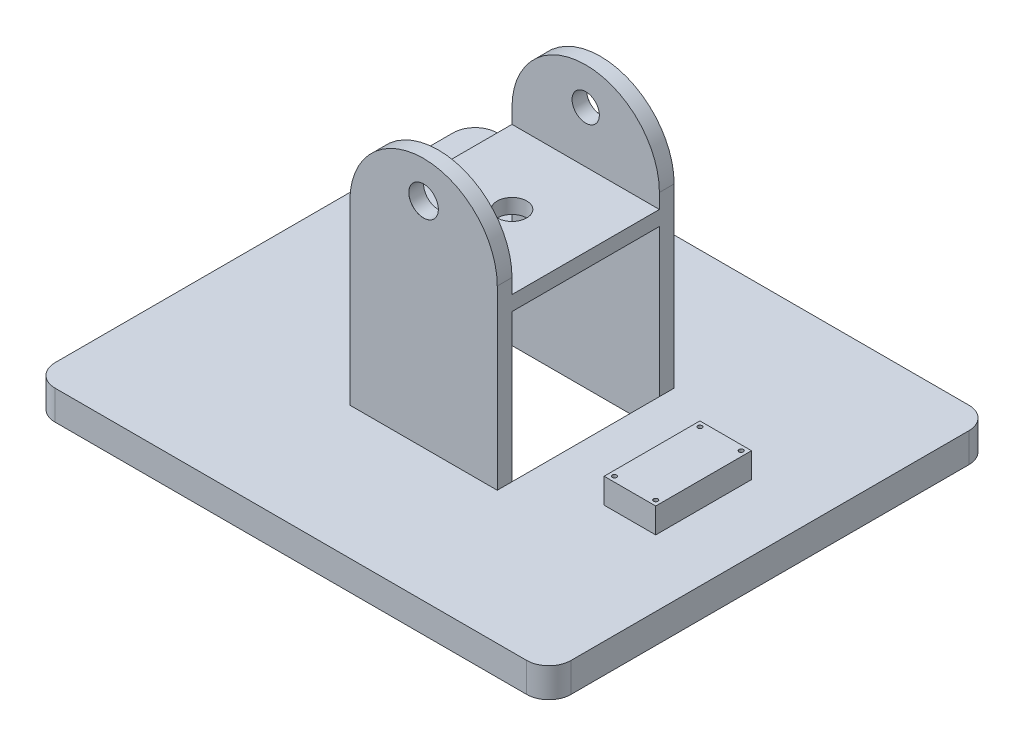
from build123d import *

# Parameters (mm, degrees)
SKETCH1_W                              = 350
SKETCH1_H                              = 300
BOSS_EXTRUDE1_DEPTH                    = 20
FILLET1_R                              = 15
SKETCH2_W                              = 100
SKETCH2_H                              = 100
CUT_EXTRUDE1_DEPTH                     = 20
BOSS_EXTRUDE2_DEPTH                    = 10
LPATTERN1_COUNT                        = 2
LPATTERN1_PITCH                        = 110
F_20_0_20_DIAMETER_HOLE2_D             = 20
F_20_0_20_DIAMETER_HOLE2_DEPTH         = 10
F_20_0_20_DIAMETER_HOLE2_CSINK_D       = 20.05
F_20_0_20_DIAMETER_HOLE2_CSINK_ANGLE   = 90
F_20_0_20_DIAMETER_HOLE2_TIP           = 6.00860619
F_18_5_18_5_DIAMETER_HOLE1_D           = 18.5
F_18_5_18_5_DIAMETER_HOLE1_DEPTH       = 10
F_18_5_18_5_DIAMETER_HOLE1_CSINK_D     = 18.55
F_18_5_18_5_DIAMETER_HOLE1_CSINK_ANGLE = 90
F_18_5_18_5_DIAMETER_HOLE1_TIP         = 5.557960726
SKETCH32_W                             = 100
SKETCH32_H                             = 10
BOSS_EXTRUDE3_DEPTH                    = 120
SKETCH37_R                             = 10
CUT_EXTRUDE2_DEPTH                     = 36.07831716
SKETCH45_W                             = 35
SKETCH45_H                             = 65
BOSS_EXTRUDE4_DEPTH                    = 17
M2_5_CLEARANCE_HOLE1_D                 = 2.9
M2_5_CLEARANCE_HOLE1_DEPTH             = 12.4
M2_5_CLEARANCE_HOLE1_CSINK_D           = 2.95
M2_5_CLEARANCE_HOLE1_CSINK_ANGLE       = 90
M2_5_CLEARANCE_HOLE1_TIP               = 0.871247898


with BuildPart() as part:
    # Sketch1 → Boss-Extrude1 (new body)
    with BuildSketch(Plane(origin=(0, 0, 0), x_dir=(1, 0, 0), z_dir=(0, 1, 0))):
        with Locations((175, -150)):
            Rectangle(SKETCH1_W, SKETCH1_H)
    extrude(amount=BOSS_EXTRUDE1_DEPTH)

    # Fillet1
    fillet1_edges = [part.edges().sort_by_distance(p)[0] for p in [
        (0, 10, 0),
        (350, 10, 0),
        (350, 10, 300),
        (0, 10, 300),
    ]]
    fillet(fillet1_edges, radius=FILLET1_R)

    # Sketch2 → Cut-Extrude1 (cut)
    with BuildSketch(Plane(origin=(0, 20, 0), x_dir=(1, 0, 0), z_dir=(0, 1, 0))):
        with Locations((175, -150)):
            Rectangle(SKETCH2_W, SKETCH2_H)
    extrude(amount=-CUT_EXTRUDE1_DEPTH, mode=Mode.SUBTRACT)

    # Sketch6 → Boss-Extrude2 (add)
    with BuildSketch(Plane.XY.offset(100)):
        with BuildLine():
            Line((125, 0), (125, 140))
            ThreePointArc((125, 140), (175, 190), (225, 140))
            Line((225, 140), (225, 0))
            Line((225, 0), (125, 0))
        make_face()
    boss_extrude2 = extrude(amount=-BOSS_EXTRUDE2_DEPTH)

    # LPattern1: Boss-Extrude2 ×2
    with Locations(*[(0, 0, i * LPATTERN1_PITCH) for i in range(1, LPATTERN1_COUNT)]):
        add(boss_extrude2)

    # Ø20.0 (20) Diameter Hole2
    with Locations(Plane.XY.offset(210)):
        with Locations((175, 165)):
            CounterSinkHole(F_20_0_20_DIAMETER_HOLE2_D / 2, F_20_0_20_DIAMETER_HOLE2_CSINK_D / 2, depth=F_20_0_20_DIAMETER_HOLE2_DEPTH, counter_sink_angle=F_20_0_20_DIAMETER_HOLE2_CSINK_ANGLE)
            with Locations((0, 0, -(F_20_0_20_DIAMETER_HOLE2_DEPTH + F_20_0_20_DIAMETER_HOLE2_TIP / 2))):  # 118° drill point
                Cone(0, F_20_0_20_DIAMETER_HOLE2_D / 2, F_20_0_20_DIAMETER_HOLE2_TIP, mode=Mode.SUBTRACT)

    # Ø18.5 (18.5) Diameter Hole1
    with Locations(Plane(origin=(0, 0, 90), x_dir=(-1, 0, 0), z_dir=(0, 0, -1))):
        with Locations((-175, 165)):
            CounterSinkHole(F_18_5_18_5_DIAMETER_HOLE1_D / 2, F_18_5_18_5_DIAMETER_HOLE1_CSINK_D / 2, depth=F_18_5_18_5_DIAMETER_HOLE1_DEPTH, counter_sink_angle=F_18_5_18_5_DIAMETER_HOLE1_CSINK_ANGLE)
            with Locations((0, 0, -(F_18_5_18_5_DIAMETER_HOLE1_DEPTH + F_18_5_18_5_DIAMETER_HOLE1_TIP / 2))):  # 118° drill point
                Cone(0, F_18_5_18_5_DIAMETER_HOLE1_D / 2, F_18_5_18_5_DIAMETER_HOLE1_TIP, mode=Mode.SUBTRACT)

    # Sketch32 → Boss-Extrude3 (add)
    with BuildSketch(Plane.XY.offset(210)):
        with Locations((175, 125)):
            Rectangle(SKETCH32_W, SKETCH32_H)
    extrude(amount=-BOSS_EXTRUDE3_DEPTH)

    # Sketch37 → Cut-Extrude2 (cut)
    with BuildSketch(Plane(origin=(0, 130, 0), x_dir=(1, 0, 0), z_dir=(0, 1, 0))):
        with Locations((175, -150)):
            Circle(SKETCH37_R)
    extrude(amount=-CUT_EXTRUDE2_DEPTH, mode=Mode.SUBTRACT)

    # Sketch45 → Boss-Extrude4 (add)
    with BuildSketch(Plane(origin=(0, 20, 0), x_dir=(1, 0, 0), z_dir=(0, 1, 0))):
        with Locations((287.5, -150)):
            Rectangle(SKETCH45_W, SKETCH45_H)
    extrude(amount=BOSS_EXTRUDE4_DEPTH)

    # M2.5 Clearance Hole1
    with Locations(Plane(origin=(0, 37, 0), x_dir=(1, 0, 0), z_dir=(0, 1, 0))):
        with Locations((273.5, -121), (301.5, -121), (301.5, -179), (273.5, -179)):
            CounterSinkHole(M2_5_CLEARANCE_HOLE1_D / 2, M2_5_CLEARANCE_HOLE1_CSINK_D / 2, depth=M2_5_CLEARANCE_HOLE1_DEPTH, counter_sink_angle=M2_5_CLEARANCE_HOLE1_CSINK_ANGLE)
            with Locations((0, 0, -(M2_5_CLEARANCE_HOLE1_DEPTH + M2_5_CLEARANCE_HOLE1_TIP / 2))):  # 118° drill point
                Cone(0, M2_5_CLEARANCE_HOLE1_D / 2, M2_5_CLEARANCE_HOLE1_TIP, mode=Mode.SUBTRACT)


solid = part.part
